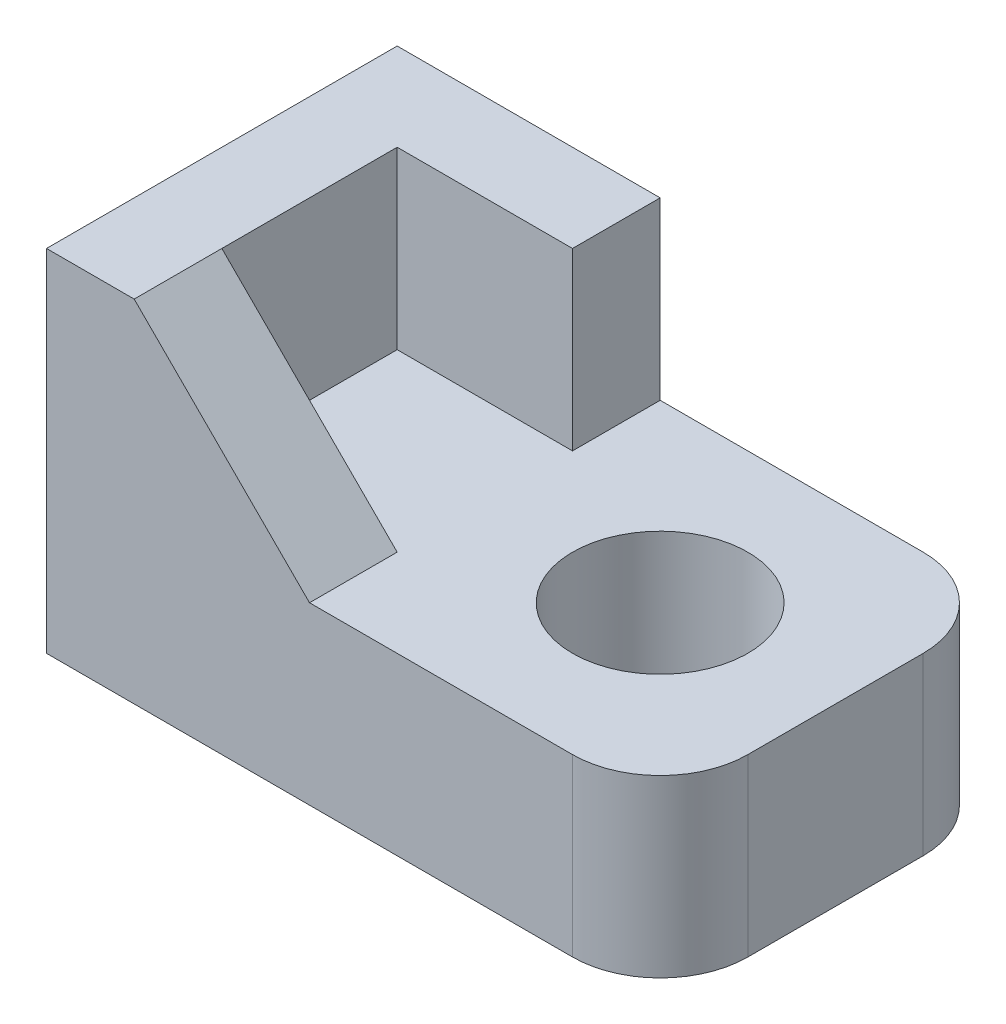
from build123d import *

# Parameters (mm, degrees)
SKETCH_1_R          = 5
EXTRUDE_1_DEPTH     = 10
EXTRUDE_2_DEPTH     = 20
CUT_EXTRUDE_1_DEPTH = 5


with BuildPart() as part:
    # 草圖1 → 填料-伸長1 (new body)
    with BuildSketch(Plane(origin=(0, 0, 0), x_dir=(1, 0, 0), z_dir=(0, 1, 0))):
        with BuildLine():
            Line((0, -10), (0, 10))
            Line((0, 10), (30, 10))
            ThreePointArc((30, 10), (33.535533906, 8.535533906), (35, 5))
            Line((35, 5), (35, 0))
            Line((35, 0), (35, -5))
            ThreePointArc((35, -5), (33.535533906, -8.535533906), (30, -10))
            Line((30, -10), (0, -10))
        make_face()
        with Locations((25, 0)):
            Circle(SKETCH_1_R, mode=Mode.SUBTRACT)
    extrude(amount=EXTRUDE_1_DEPTH)

    # 草圖4 → 填料-伸長2 (add)
    with BuildSketch(Plane(origin=(0, 0, 0), x_dir=(1, 0, 0), z_dir=(0, 1, 0))):
        Polygon((0, 0), (0, 10), (15, 10), (15, 5), (5, 5), (5, -5), (15, -5), (15, -10), (0, -10), align=None)
    extrude(amount=EXTRUDE_2_DEPTH)

    # 草圖5 → 除料-伸長1 (cut)
    with BuildSketch(Plane.XY.offset(10)):
        Polygon((15, 10), (5, 20), (15, 20), align=None)
    extrude(amount=-CUT_EXTRUDE_1_DEPTH, mode=Mode.SUBTRACT)


solid = part.part
